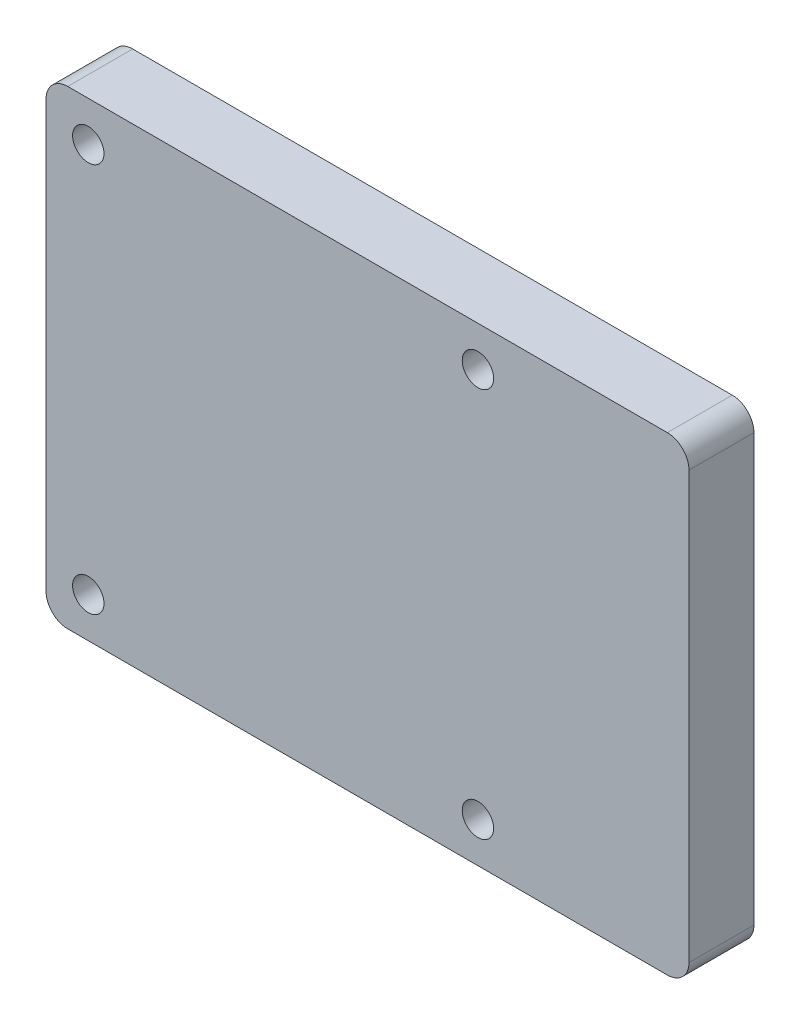
from build123d import *

# Parameters (mm, degrees)
SKETCH_1_W          = 59.4
SKETCH_1_H          = 43.4
EXTRUDE_1_DEPTH     = 6
SKETCH_2_W          = 56.4
SKETCH_2_H          = 40.4
CUT_EXTRUDE_1_DEPTH = 5
EXTRUDE_2_DEPTH     = 3.2
EXTRUDE_3_DEPTH     = 3.2
EXTRUDE_4_DEPTH     = 3.2
EXTRUDE_5_DEPTH     = 3.2
FILLET_1_R          = 1
FILLET_2_R          = 2
SKETCH_7_R          = 1.45
CUT_EXTRUDE_2_DEPTH = 20


with BuildPart() as part:
    # 草图1 → 凸台-拉伸1 (new body)
    with BuildSketch(Plane(origin=(0, 0, -6), x_dir=(-1, 0, 0), z_dir=(0, 0, -1))):
        Rectangle(SKETCH_1_W, SKETCH_1_H)
    extrude(amount=-EXTRUDE_1_DEPTH)

    # 草图2 → 切除-拉伸1 (cut)
    with BuildSketch(Plane(origin=(0, 0, -6), x_dir=(-1, 0, 0), z_dir=(0, 0, -1))):
        Rectangle(SKETCH_2_W, SKETCH_2_H)
    extrude(amount=-CUT_EXTRUDE_1_DEPTH, mode=Mode.SUBTRACT)

    # 草图3 → 凸台-拉伸2 (add)
    with BuildSketch(Plane(origin=(0, 0, -1), x_dir=(-1, 0, 0), z_dir=(0, 0, -1))):
        with BuildLine():
            Line((-13.62928564, 20.2), (-6.77071436, 20.2))
            ThreePointArc((-6.77071436, 20.2), (-7.932609364, 19.648683298), (-8.240408206, 18.4))
            ThreePointArc((-8.240408206, 18.4), (-10.2, 16), (-12.159591794, 18.4))
            ThreePointArc((-12.159591794, 18.4), (-12.467390636, 19.648683298), (-13.62928564, 20.2))
        make_face()
    extrude(amount=EXTRUDE_2_DEPTH)

    # 草图4 → 凸台-拉伸3 (add)
    with BuildSketch(Plane(origin=(0, 0, -1), x_dir=(-1, 0, 0), z_dir=(0, 0, -1))):
        with BuildLine():
            Line((22.37071436, 20.2), (28.2, 20.2))
            Line((28.2, 20.2), (28.2, 14.617693095))
            ThreePointArc((28.2, 14.617693095), (27.6141741, 15.806930546), (26.314285714, 16.067253197))
            ThreePointArc((26.314285714, 16.067253197), (24.427901488, 16.544889808), (23.840408206, 18.4))
            ThreePointArc((23.840408206, 18.4), (23.532609364, 19.648683298), (22.37071436, 20.2))
        make_face()
    extrude(amount=EXTRUDE_3_DEPTH)

    # 草图5 → 凸台-拉伸4 (add)
    with BuildSketch(Plane(origin=(0, 0, -1), x_dir=(-1, 0, 0), z_dir=(0, 0, -1))):
        with BuildLine():
            Line((28.2, -14.617693095), (28.2, -20.2))
            Line((28.2, -20.2), (22.37071436, -20.2))
            ThreePointArc((22.37071436, -20.2), (23.532609364, -19.648683298), (23.840408206, -18.4))
            ThreePointArc((23.840408206, -18.4), (24.427901488, -16.544889808), (26.314285714, -16.067253197))
            ThreePointArc((26.314285714, -16.067253197), (27.6141741, -15.806930546), (28.2, -14.617693095))
        make_face()
    extrude(amount=EXTRUDE_4_DEPTH)

    # 草图6 → 凸台-拉伸5 (add)
    with BuildSketch(Plane(origin=(0, 0, -1), x_dir=(-1, 0, 0), z_dir=(0, 0, -1))):
        with BuildLine():
            Line((-6.77071436, -20.2), (-13.62928564, -20.2))
            ThreePointArc((-13.62928564, -20.2), (-12.467390636, -19.648683298), (-12.159591794, -18.4))
            ThreePointArc((-12.159591794, -18.4), (-10.2, -16), (-8.240408206, -18.4))
            ThreePointArc((-8.240408206, -18.4), (-7.932609364, -19.648683298), (-6.77071436, -20.2))
        make_face()
    extrude(amount=EXTRUDE_5_DEPTH)

    # 圆角1
    fillet_1_edges = [part.edges().sort_by_distance(p)[0] for p in [
        (28.2, -20.2, -3.5),
        (28.2, 20.2, -3.5),
        (-28.2, 20.2, -5.1),
        (-28.2, -20.2, -5.1),
    ]]
    fillet(fillet_1_edges, radius=FILLET_1_R)

    # 圆角2
    fillet_2_edges = [part.edges().sort_by_distance(p)[0] for p in [
        (-29.7, 21.7, -3),
        (-29.7, -21.7, -3),
        (29.7, -21.7, -3),
        (29.7, 21.7, -3),
    ]]
    fillet(fillet_2_edges, radius=FILLET_2_R)

    # 草图7 → 切除-拉伸2 (cut)
    with BuildSketch(Plane(origin=(0, 0, -4.2), x_dir=(-1, 0, 0), z_dir=(0, 0, -1))):
        with Locations((-10.2, 18)):
            Circle(SKETCH_7_R)
        with Locations((-10.2, -18)):
            Circle(SKETCH_7_R)
        with Locations((25.8, 18)):
            Circle(SKETCH_7_R)
        with Locations((25.8, -18)):
            Circle(SKETCH_7_R)
    extrude(amount=-CUT_EXTRUDE_2_DEPTH, mode=Mode.SUBTRACT)


solid = part.part
